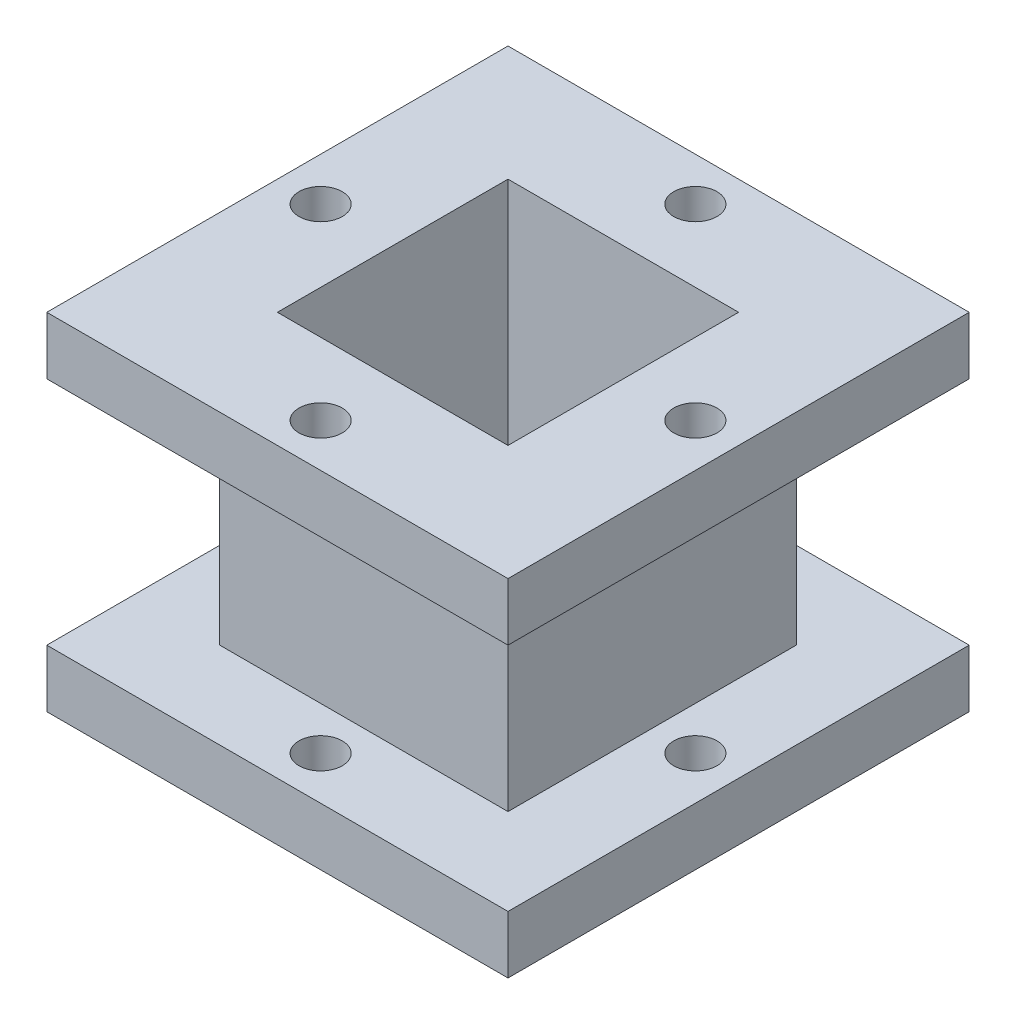
from build123d import *

# Parameters (mm, degrees)
SKETCH1_W           = 50.8
SKETCH1_H           = 50.8
BOSS_EXTRUDE1_DEPTH = 6.35
SKETCH2_W           = 31.75
SKETCH2_H           = 31.75
BOSS_EXTRUDE2_DEPTH = 25.4
SKETCH3_W           = 50.8
SKETCH3_H           = 50.8
BOSS_EXTRUDE3_DEPTH = 6.35
SKETCH4_W           = 25.4
SKETCH4_H           = 25.4
CUT_EXTRUDE1_DEPTH  = 53.363441445
SKETCH5_R           = 2.38125
CUT_EXTRUDE2_DEPTH  = 53.363441445
CIRPATTERN1_COUNT   = 4
SCALE1_SCALE        = 1.02


with BuildPart() as part:
    # Sketch1 → Boss-Extrude1 (new body)
    with BuildSketch(Plane(origin=(0, 0, 0), x_dir=(1, 0, 0), z_dir=(0, 1, 0))):
        Rectangle(SKETCH1_W, SKETCH1_H)
    extrude(amount=BOSS_EXTRUDE1_DEPTH)

    # Sketch2 → Boss-Extrude2 (add)
    with BuildSketch(Plane(origin=(0, 6.35, 0), x_dir=(1, 0, 0), z_dir=(0, 1, 0))):
        Rectangle(SKETCH2_W, SKETCH2_H)
    extrude(amount=BOSS_EXTRUDE2_DEPTH)

    # Sketch3 → Boss-Extrude3 (add)
    with BuildSketch(Plane(origin=(0, 31.75, 0), x_dir=(1, 0, 0), z_dir=(0, 1, 0))):
        Rectangle(SKETCH3_W, SKETCH3_H)
    extrude(amount=BOSS_EXTRUDE3_DEPTH)

    # Sketch4 → Cut-Extrude1 (cut, through all)
    with BuildSketch(Plane(origin=(0, 38.1, 0), x_dir=(1, 0, 0), z_dir=(0, 1, 0))):
        Rectangle(SKETCH4_W, SKETCH4_H)
    extrude(amount=-CUT_EXTRUDE1_DEPTH, mode=Mode.SUBTRACT)

    # Sketch5 → Cut-Extrude2 (cut, through all)
    with BuildSketch(Plane(origin=(0, 38.1, 0), x_dir=(1, 0, 0), z_dir=(0, 1, 0))):
        with Locations((0, -20.6375)):
            Circle(SKETCH5_R)
    cut_extrude2 = extrude(amount=-CUT_EXTRUDE2_DEPTH, mode=Mode.SUBTRACT)

    # CirPattern1: Cut-Extrude2 ×4 about axis
    cirpattern1_axis = Axis((0, -6.908338813, 0), (0, 1, 0))
    for i in range(1, CIRPATTERN1_COUNT):
        add(cut_extrude2.rotate(cirpattern1_axis, i * 360 / CIRPATTERN1_COUNT), mode=Mode.SUBTRACT)


with BuildPart() as part_1:
    # Scale1: scaled about (0, 19.05, 0)
    add(part.part.scale(SCALE1_SCALE).moved(Location((0, -0.381, 0))))


solid = part_1.part
